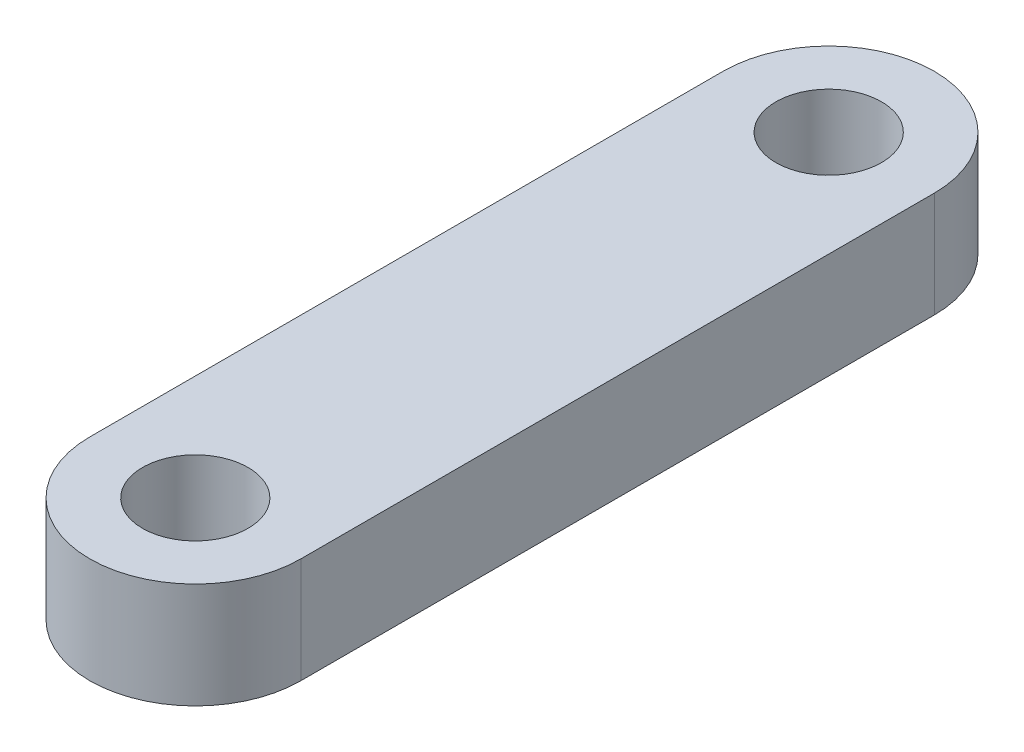
from build123d import *

# Parameters (mm, degrees)
SKETCH1_R           = 6.35
BOSS_EXTRUDE1_DEPTH = 12.7


with BuildPart() as part:
    # Sketch1 → Boss-Extrude1 (new body)
    with BuildSketch(Plane(origin=(0, 0, 0), x_dir=(1, 0, 0), z_dir=(0, 1, 0))):
        with BuildLine():
            Line((0, 0), (0, -76.2))
            ThreePointArc((0, -76.2), (12.7, -88.9), (25.4, -76.2))
            Line((25.4, -76.2), (25.4, 0))
            ThreePointArc((25.4, 0), (12.7, 12.7), (0, 0))
        make_face()
        with Locations((12.7, 0)):
            Circle(SKETCH1_R, mode=Mode.SUBTRACT)
        with Locations((12.7, -76.2)):
            Circle(SKETCH1_R, mode=Mode.SUBTRACT)
    extrude(amount=BOSS_EXTRUDE1_DEPTH)


solid = part.part
